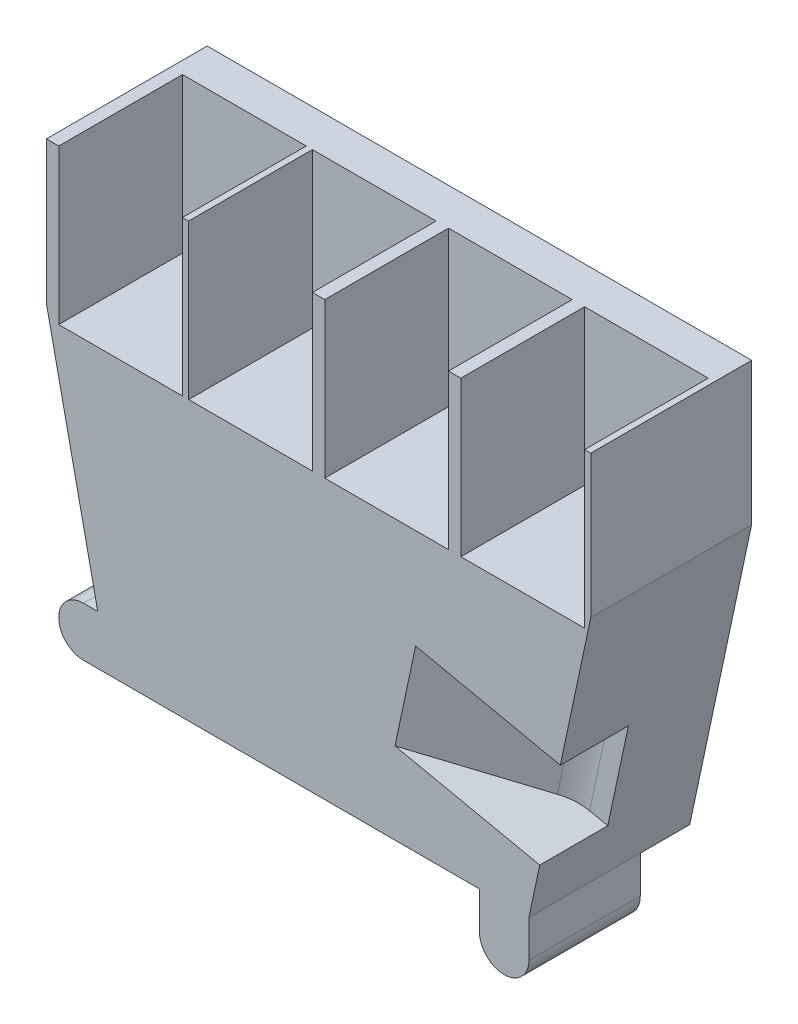
from build123d import *

# Parameters (mm, degrees)
EXTRUDE_1_DEPTH      = 26
SKETCH_4_W           = 20
SKETCH_4_H           = 20
CUT_EXTRUDE_5_DEPTH  = 25
CUT_EXTRUDE_6_DEPTH  = 8
CUT_EXTRUDE_8_DEPTH  = 16
SKETCH_12_W          = 8
SKETCH_12_H          = 10
EXTRUDE_2_DEPTH      = 26
CUT_EXTRUDE_9_DEPTH  = 26
SKETCH_14_W          = 8
SKETCH_14_H          = 12.86312638
CUT_EXTRUDE_10_DEPTH = 95.212525707


with BuildPart() as part:
    # 草图1 → 凸台-拉伸1 (new body)
    with BuildSketch(Plane.XY):
        Polygon((-34, -24), (34, -24), (44, 23), (44, 46), (-44, 46), (-44, 23), align=None)
    extrude(amount=EXTRUDE_1_DEPTH)

    # 草图4 → 切除-拉伸5 (cut)
    with BuildSketch(Plane(origin=(0, 46, 0), x_dir=(1, 0, 0), z_dir=(0, 1, 0))):
        with Locations((33, -16)):
            Rectangle(SKETCH_4_W, SKETCH_4_H)
        with Locations((11, -16)):
            Rectangle(SKETCH_4_W, SKETCH_4_H)
        with Locations((-11, -16)):
            Rectangle(SKETCH_4_W, SKETCH_4_H)
        with Locations((-32, -16)):
            Rectangle(SKETCH_4_W, SKETCH_4_H)
    extrude(amount=-CUT_EXTRUDE_5_DEPTH, mode=Mode.SUBTRACT)

    # Sketch 3D_6 → 切除-拉伸6 (cut, symmetric)
    with BuildSketch(Plane(origin=(34.478414998, -7.335832978, 14.99907516), x_dir=(0.5895982688198705, -0.12544644017993214, 0.7978954016979886), z_dir=(-0.20810764446495697, -0.9781059289848145, -6.6559639472978385e-12))):
        with BuildLine():
            Line((0, 0), (6.376045072, -8.439700449))
            Line((6.376045072, -8.439700449), (17.547318622, 0))
            Line((17.547318622, 0), (11.17127355, 8.439700449))
            Line((11.17127355, 8.439700449), (6.348906145, 14.822863662))
            Line((6.348906145, 14.822863662), (1.560795809, 11.205530619))
            ThreePointArc((1.560795809, 11.205530619), (-1.540343474, 5.926016705), (0, 0))
        make_face()
    extrude(amount=CUT_EXTRUDE_6_DEPTH, both=True, mode=Mode.SUBTRACT)

    # 草图11 → 切除-拉伸8 (cut)
    with BuildSketch(Plane(origin=(-1.664861156, -7.824847432, 0), x_dir=(0.9781059289845859, -0.2081076444660318, -1.1269708570671002e-12), z_dir=(0.20810764446603178, 0.9781059289845858, 5.296763028184159e-12))):
        with BuildLine():
            Line((31.200844283, -16.100518909), (14.333584528, -26))
            Line((14.333584528, -26), (32.666556858, -30.571318601))
            ThreePointArc((32.666556858, -30.571318601), (42.196349228, -26.968728166), (40.460809076, -16.92962956))
            Line((40.460809076, -16.92962956), (38.250185053, -14.99907516))
            Line((38.250185053, -14.99907516), (35.250185053, -15))
            ThreePointArc((35.250185053, -15), (33.152072655, -15.280030806), (31.200844283, -16.100518909))
        make_face()
    extrude(amount=CUT_EXTRUDE_8_DEPTH, mode=Mode.SUBTRACT)

    # 草图12 → 凸台-拉伸2 (add)
    with BuildSketch(Plane(origin=(0, 0, 0), x_dir=(-1, 0, 0), z_dir=(0, 0, -1))):
        with Locations((-30, -29)):
            Rectangle(SKETCH_12_W, SKETCH_12_H)
        with BuildLine():
            Line((34, -24), (38, -24))
            ThreePointArc((38, -24), (42, -20), (38, -16))
            Line((38, -16), (34, -16))
            Line((34, -16), (34, -24))
        make_face()
    extrude(amount=-EXTRUDE_2_DEPTH)

    # 草图13 → 切除-拉伸9 (cut)
    with BuildSketch(Plane(origin=(0, 0, 0), x_dir=(-1, 0, 0), z_dir=(0, 0, -1))):
        with BuildLine():
            Line((-34, -30), (-34, -35.772176756))
            Line((-34, -35.772176756), (-26, -35.772176756))
            Line((-26, -35.772176756), (-26, -30))
            ThreePointArc((-26, -30), (-30, -34), (-34, -30))
        make_face()
        with BuildLine():
            Line((26, -30), (26, -35.772176756))
            Line((26, -35.772176756), (34, -35.772176756))
            Line((34, -35.772176756), (34, -30))
            ThreePointArc((34, -30), (30, -34), (26, -30))
        make_face()
    extrude(amount=-CUT_EXTRUDE_9_DEPTH, mode=Mode.SUBTRACT)

    # 草图14 → 切除-拉伸10 (cut, through all)
    with BuildSketch(Plane(origin=(34, 0, 0), x_dir=(0, 0, -1), z_dir=(1, 0, 0))):
        with Locations((-4, -30.43156319)):
            Rectangle(SKETCH_14_W, SKETCH_14_H)
    extrude(amount=-CUT_EXTRUDE_10_DEPTH, mode=Mode.SUBTRACT)


solid = part.part
